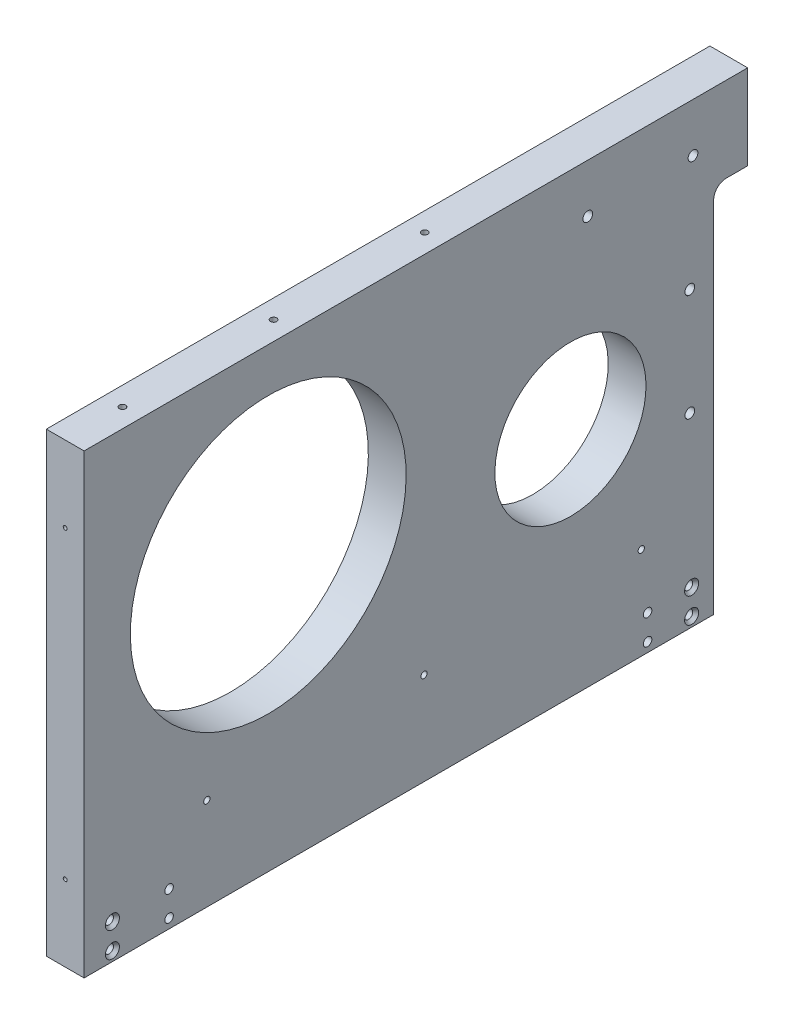
from build123d import *

# Parameters (mm, degrees)
SKETCH1_W                                         = 19.05
SKETCH1_H                                         = 230.1875
BOSS_EXTRUDE1_DEPTH                               = 342.9
SKETCH2_W                                         = 19.05
SKETCH2_H                                         = 156.880836743
CUT_EXTRUDE1_DEPTH                                = 8.255
F_15_64_0_23438_DIAMETER_HOLE3_D                  = 5.953252
F_15_64_0_23438_DIAMETER_HOLE3_DEPTH              = 12.7
F_15_64_0_23438_DIAMETER_HOLE3_TIP                = 1.788537341
F_5_64_0_07813_DIAMETER_HOLE1_D                   = 3.175
F_5_64_0_07813_DIAMETER_HOLE1_DEPTH               = 38.1
F_5_64_0_07813_DIAMETER_HOLE1_CSINK_D             = 10.16
F_5_64_0_07813_DIAMETER_HOLE1_CSINK_ANGLE         = 82
F_5_64_0_07813_DIAMETER_HOLE1_TIP                 = 0.953866233
F_5_64_0_07813_DIAMETER_HOLE2_D                   = 1.984502
F_5_64_0_07813_DIAMETER_HOLE2_DEPTH               = 38.1
F_5_64_0_07813_DIAMETER_HOLE2_CSINK_D             = 10.16
F_5_64_0_07813_DIAMETER_HOLE2_CSINK_ANGLE         = 82
F_5_64_0_07813_DIAMETER_HOLE2_TIP                 = 0.59620455
F_1_8_0_125_DIAMETER_HOLE1_D                      = 3.175
F_1_8_0_125_DIAMETER_HOLE1_DEPTH                  = 19.05
F_1_8_0_125_DIAMETER_HOLE1_CSINK_D                = 10.16
F_1_8_0_125_DIAMETER_HOLE1_CSINK_ANGLE            = 90
F_8_CLEARANCE_HOLE1_D                             = 4.9149
F_8_CLEARANCE_HOLE1_DEPTH                         = 19.05
CSK_FOR_6_FLAT_HEAD_MACHINE_SCREW_100_D           = 4.3053
CSK_FOR_6_FLAT_HEAD_MACHINE_SCREW_100_DEPTH       = 19.05
CSK_FOR_6_FLAT_HEAD_MACHINE_SCREW_100_CSINK_D     = 7.0866
CSK_FOR_6_FLAT_HEAD_MACHINE_SCREW_100_CSINK_ANGLE = 82
CSK_FOR_6_FLAT_HEAD_MACHINE_SCREW1_D              = 4.3053
CSK_FOR_6_FLAT_HEAD_MACHINE_SCREW1_DEPTH          = 19.05
CSK_FOR_6_FLAT_HEAD_MACHINE_SCREW1_CSINK_D        = 7.0866
CSK_FOR_6_FLAT_HEAD_MACHINE_SCREW1_CSINK_ANGLE    = 82
CUT_EXTRUDE3_REACH                                = 21.05
SKETCH22_W                                        = 25.4
SKETCH22_H                                        = 187.3885
FILLET1_R                                         = 6.35
F_8_CLEARANCE_HOLE2_D                             = 4.9149
CUT_EXTRUDE2_REACH                                = 21.05
SKETCH17_R                                        = 69.5325
SKETCH17_R_2                                      = 38.1


with BuildPart() as part:
    # Sketch1 → Boss-Extrude1 (new body)
    with BuildSketch(Plane.XY):
        with Locations((-281.19705, -118.26875)):
            Rectangle(SKETCH1_W, SKETCH1_H)
    extrude(amount=BOSS_EXTRUDE1_DEPTH)

    # Sketch2 → Cut-Extrude1 (cut)
    with BuildSketch(Plane.XY):
        with Locations((-281.19705, -81.615418372)):
            Rectangle(SKETCH2_W, SKETCH2_H)
    extrude(amount=CUT_EXTRUDE1_DEPTH, mode=Mode.SUBTRACT)

    # 15/64 (0.23438) Diameter Hole3
    with Locations(Plane(origin=(-182.40375, 1936.853954382, -6.35), x_dir=(1, 0, 0), z_dir=(0, 0, -1))):
        with Locations((-262.8265, 2051.088542934), (-262.8265, 2014.068680083), (-262.8265, 1977.048817232), (-98.7933, 2115.959791125), (-98.7933, 2151.166454382)):
            Hole(F_15_64_0_23438_DIAMETER_HOLE3_D / 2, depth=F_15_64_0_23438_DIAMETER_HOLE3_DEPTH)
            with Locations((0, 0, -(F_15_64_0_23438_DIAMETER_HOLE3_DEPTH + F_15_64_0_23438_DIAMETER_HOLE3_TIP / 2))):  # 118° drill point
                Cone(0, F_15_64_0_23438_DIAMETER_HOLE3_D / 2, F_15_64_0_23438_DIAMETER_HOLE3_TIP, mode=Mode.SUBTRACT)

    # 5/64 (0.07813) Diameter Hole1
    with Locations(Plane(origin=(-182.40375, 15.875, 6471.459863233), x_dir=(1, 0, 0), z_dir=(0, 1, 0))):
        with Locations((-262.8265, 6157.452363233), (-98.7933, 6157.452363233), (-262.8265, 6233.652363233), (-98.7933, 6233.652363233), (-262.8265, 6309.852363233), (-98.7933, 6309.852363233), (-267.97, 6119.034863233), (-115.57, 6119.034863233), (-1.27, 6119.034863233), (113.03, 6119.034863233), (265.43, 6119.034863233), (96.2533, 6309.852363233), (260.2865, 6309.852363233), (96.2533, 6233.652363233), (260.2865, 6233.652363233), (96.2533, 6157.452363233), (260.2865, 6157.452363233)):
            CounterSinkHole(F_5_64_0_07813_DIAMETER_HOLE1_D / 2, F_5_64_0_07813_DIAMETER_HOLE1_CSINK_D / 2, depth=F_5_64_0_07813_DIAMETER_HOLE1_DEPTH, counter_sink_angle=F_5_64_0_07813_DIAMETER_HOLE1_CSINK_ANGLE)
            with Locations((0, 0, -(F_5_64_0_07813_DIAMETER_HOLE1_DEPTH + F_5_64_0_07813_DIAMETER_HOLE1_TIP / 2))):  # 118° drill point
                Cone(0, F_5_64_0_07813_DIAMETER_HOLE1_D / 2, F_5_64_0_07813_DIAMETER_HOLE1_TIP, mode=Mode.SUBTRACT)

    # 5/64 (0.07813) Diameter Hole2
    with Locations(Plane(origin=(-182.40375, 1936.853954382, 361.95), x_dir=(-1, 0, 0), z_dir=(0, 0, 1))):
        with Locations((-263.392416364, 1965.434682144), (262.8265, 1964.708862949), (262.8265, 2063.428497217), (98.7933, 2131.851871048), (98.7933, 1978.393537715), (53.56098, 2123.543954382), (-53.56098, 2123.543954382), (-99.322089753, 1978.666800322), (-98.898757225, 2132.124549748), (-263.120086856, 2064.153940785)):
            CounterSinkHole(F_5_64_0_07813_DIAMETER_HOLE2_D / 2, F_5_64_0_07813_DIAMETER_HOLE2_CSINK_D / 2, depth=F_5_64_0_07813_DIAMETER_HOLE2_DEPTH, counter_sink_angle=F_5_64_0_07813_DIAMETER_HOLE2_CSINK_ANGLE)
            with Locations((0, 0, -(F_5_64_0_07813_DIAMETER_HOLE2_DEPTH + F_5_64_0_07813_DIAMETER_HOLE2_TIP / 2))):  # 118° drill point
                Cone(0, F_5_64_0_07813_DIAMETER_HOLE2_D / 2, F_5_64_0_07813_DIAMETER_HOLE2_TIP, mode=Mode.SUBTRACT)

    # 1/8 (0.125) Diameter Hole1
    with Locations(Plane.ZY.offset(290.72205)):
        with Locations((61.9125, -186.69), (280.9875, -186.69), (171.45, -186.69)):
            CounterSinkHole(F_1_8_0_125_DIAMETER_HOLE1_D / 2, F_1_8_0_125_DIAMETER_HOLE1_CSINK_D / 2, depth=F_1_8_0_125_DIAMETER_HOLE1_DEPTH, counter_sink_angle=F_1_8_0_125_DIAMETER_HOLE1_CSINK_ANGLE)

    # #8 Clearance Hole1
    with Locations(Plane(origin=(-271.67205, 0, 0), x_dir=(0, 0, -1), z_dir=(1, 0, 0))):
        with Locations((-88.9, -27.7495), (-35.8275, -27.7495)):
            Hole(F_8_CLEARANCE_HOLE1_D / 2, depth=F_8_CLEARANCE_HOLE1_DEPTH)

    # CSK for #6 Flat Head Machine Screw (100)1
    with Locations(Plane(origin=(-271.67205, 0, 0), x_dir=(0, 0, -1), z_dir=(1, 0, 0))):
        with Locations((-36.5125, -215.9), (-36.5125, -228.6), (-328.6125, -215.9), (-328.6125, -228.6)):
            CounterSinkHole(CSK_FOR_6_FLAT_HEAD_MACHINE_SCREW_100_D / 2, CSK_FOR_6_FLAT_HEAD_MACHINE_SCREW_100_CSINK_D / 2, depth=CSK_FOR_6_FLAT_HEAD_MACHINE_SCREW_100_DEPTH, counter_sink_angle=CSK_FOR_6_FLAT_HEAD_MACHINE_SCREW_100_CSINK_ANGLE)

    # CSK for #6 Flat Head Machine Screw1
    with Locations(Plane.ZY.offset(290.72205)):
        with Locations((58.7375, -228.6), (58.7375, -215.9), (300.0375, -228.6), (300.0375, -215.9)):
            CounterSinkHole(CSK_FOR_6_FLAT_HEAD_MACHINE_SCREW1_D / 2, CSK_FOR_6_FLAT_HEAD_MACHINE_SCREW1_CSINK_D / 2, depth=CSK_FOR_6_FLAT_HEAD_MACHINE_SCREW1_DEPTH, counter_sink_angle=CSK_FOR_6_FLAT_HEAD_MACHINE_SCREW1_CSINK_ANGLE)

    # Sketch22 → Cut-Extrude3 (cut, up to next)
    with BuildSketch(Plane.ZY.offset(290.72205), mode=Mode.PRIVATE) as cut_extrude3_sk1:
        with Locations((12.7, -139.66825)):
            Rectangle(SKETCH22_W, SKETCH22_H)
    cut_extrude3_tool1 = extrude(cut_extrude3_sk1.sketch, amount=-CUT_EXTRUDE3_REACH, mode=Mode.PRIVATE) & part.part
    add(cut_extrude3_tool1.solids().sort_by_distance((-290.72205, -139.66825, 12.7))[0], mode=Mode.SUBTRACT)

    # Fillet1
    fillet1_edges = [part.edges().sort_by_distance(p)[0] for p in [
        (-281.19705, -45.974, 25.4),
    ]]
    fillet(fillet1_edges, radius=FILLET1_R)

    # #8 Clearance Hole2 (through all)
    with Locations(Plane(origin=(-271.67205, 0, 0), x_dir=(0, 0, -1), z_dir=(1, 0, 0))):
        with Locations((-37.44755, -139.371990921), (-37.44755, -85.396990921)):
            Hole(F_8_CLEARANCE_HOLE2_D / 2)

    # Sketch17 → Cut-Extrude2 (cut, up to next)
    with BuildSketch(Plane.ZY.offset(290.72205), mode=Mode.PRIVATE) as cut_extrude2_sk1:
        with Locations((250.03125, -94.9325)):
            Circle(SKETCH17_R)
    cut_extrude2_tool1 = extrude(cut_extrude2_sk1.sketch, amount=-CUT_EXTRUDE2_REACH, mode=Mode.PRIVATE) & part.part
    add(cut_extrude2_tool1.solids().sort_by_distance((-290.72205, -94.9325, 250.03125))[0], mode=Mode.SUBTRACT)
    # Sketch17 → Cut-Extrude2 (cut, up to next)
    with BuildSketch(Plane.ZY.offset(290.72205), mode=Mode.PRIVATE) as cut_extrude2_sk2:
        with Locations((97.63125, -116.332)):
            Circle(SKETCH17_R_2)
    cut_extrude2_tool2 = extrude(cut_extrude2_sk2.sketch, amount=-CUT_EXTRUDE2_REACH, mode=Mode.PRIVATE) & part.part
    add(cut_extrude2_tool2.solids().sort_by_distance((-290.72205, -116.332, 97.63125))[0], mode=Mode.SUBTRACT)


solid = part.part
